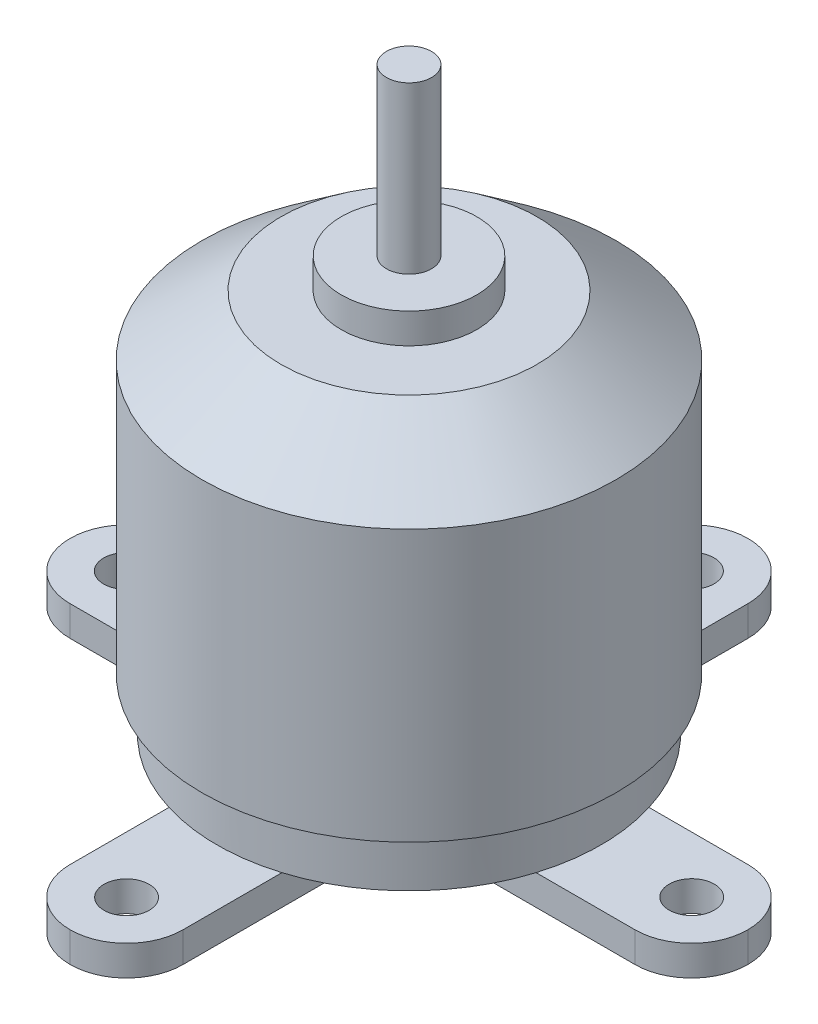
from build123d import *

# Parameters (mm, degrees)
CROQUIS1_R                       = 13.75
SALIENTE_EXTRUIR1_DEPTH          = 18
CROQUIS3_R                       = 8.5
SALIENTE_EXTRUIR2_DEPTH          = 4
CROQUIS4_R                       = 4.5
SALIENTE_EXTRUIR3_DEPTH          = 2
CROQUIS5_R                       = 1.5
SALIENTE_EXTRUIR4_DEPTH          = 11
CROQUIS7_R                       = 12.75
SALIENTE_EXTRUIR5_DEPTH          = 3.5
CROQUIS8_R                       = 5
SALIENTE_EXTRUIR6_DEPTH          = 2
TALADRO_DE_MARGEN_PARA_M11_D     = 3
TALADRO_DE_MARGEN_PARA_M11_DEPTH = 5


with BuildPart() as part:
    # Croquis1 → Saliente-Extruir1 (new body)
    with BuildSketch(Plane(origin=(0, 0, 0), x_dir=(1, 0, 0), z_dir=(0, 1, 0))):
        Circle(CROQUIS1_R)
    extrude(amount=SALIENTE_EXTRUIR1_DEPTH)

    # Croquis3 → Saliente-Extruir2 (add)
    with BuildSketch(Plane(origin=(0, 18, 0), x_dir=(1, 0, 0), z_dir=(0, 1, 0))):
        Circle(CROQUIS3_R)
    extrude(amount=SALIENTE_EXTRUIR2_DEPTH)

    # Croquis4 → Saliente-Extruir3 (add)
    with BuildSketch(Plane(origin=(0, 22, 0), x_dir=(1, 0, 0), z_dir=(0, 1, 0))):
        Circle(CROQUIS4_R)
    extrude(amount=SALIENTE_EXTRUIR3_DEPTH)

    # Croquis5 → Saliente-Extruir4 (add)
    with BuildSketch(Plane(origin=(0, 24, 0), x_dir=(1, 0, 0), z_dir=(0, 1, 0))):
        Circle(CROQUIS5_R)
    extrude(amount=SALIENTE_EXTRUIR4_DEPTH)

    # Croquis6 → Revolución1 (revolve)
    with BuildSketch(Plane.XY):
        Polygon((13.75, 18), (8.5, 22), (8.5, 18), align=None)
    revolve(axis=Axis((0, 18, 0), (0, -1, 0)))

    # Croquis7 → Saliente-Extruir5 (add)
    with BuildSketch(Plane.XZ):
        Circle(CROQUIS7_R)
    extrude(amount=SALIENTE_EXTRUIR5_DEPTH)

    # Croquis8 → Saliente-Extruir6 (add)
    with BuildSketch(Plane.XZ.offset(3.5)):
        with BuildLine():
            Line((7.49, 3.75), (18.76, 3.75))
            ThreePointArc((18.76, 3.75), (21.404579362, 2.654579362), (22.5, 0.01))
            Line((22.5, 0.01), (22.5, -0.01))
            ThreePointArc((22.5, -0.01), (21.404579362, -2.654579362), (18.76, -3.75))
            Line((18.76, -3.75), (7.49, -3.75))
            ThreePointArc((7.49, -3.75), (4.845420638, -4.845420638), (3.75, -7.49))
            Line((3.75, -7.49), (3.75, -18.76))
            ThreePointArc((3.75, -18.76), (2.654579362, -21.404579362), (0.01, -22.5))
            Line((0.01, -22.5), (-0.01, -22.5))
            ThreePointArc((-0.01, -22.5), (-2.654579362, -21.404579362), (-3.75, -18.76))
            Line((-3.75, -18.76), (-3.75, -7.49))
            ThreePointArc((-3.75, -7.49), (-4.845420638, -4.845420638), (-7.49, -3.75))
            Line((-7.49, -3.75), (-18.76, -3.75))
            ThreePointArc((-18.76, -3.75), (-21.404579362, -2.654579362), (-22.5, -0.01))
            Line((-22.5, -0.01), (-22.5, 0.01))
            ThreePointArc((-22.5, 0.01), (-21.404579362, 2.654579362), (-18.76, 3.75))
            Line((-18.76, 3.75), (-7.49, 3.75))
            ThreePointArc((-7.49, 3.75), (-4.845420638, 4.845420638), (-3.75, 7.49))
            Line((-3.75, 7.49), (-3.75, 18.76))
            ThreePointArc((-3.75, 18.76), (-2.654579362, 21.404579362), (-0.01, 22.5))
            Line((-0.01, 22.5), (0.01, 22.5))
            ThreePointArc((0.01, 22.5), (2.654579362, 21.404579362), (3.75, 18.76))
            Line((3.75, 18.76), (3.75, 7.49))
            ThreePointArc((3.75, 7.49), (4.845420638, 4.845420638), (7.49, 3.75))
        make_face()
        Circle(CROQUIS8_R, mode=Mode.SUBTRACT)
    extrude(amount=SALIENTE_EXTRUIR6_DEPTH)

    # Taladro de margen para M11
    with Locations(Plane(origin=(0, -5.5, 0), x_dir=(-1, 0, 0), z_dir=(0, -1, 0))):
        with Locations((0.01, 18.76), (-18.76, 0.01), (-0.01, -18.76), (18.76, -0.01)):
            Hole(TALADRO_DE_MARGEN_PARA_M11_D / 2, depth=TALADRO_DE_MARGEN_PARA_M11_DEPTH)


solid = part.part
